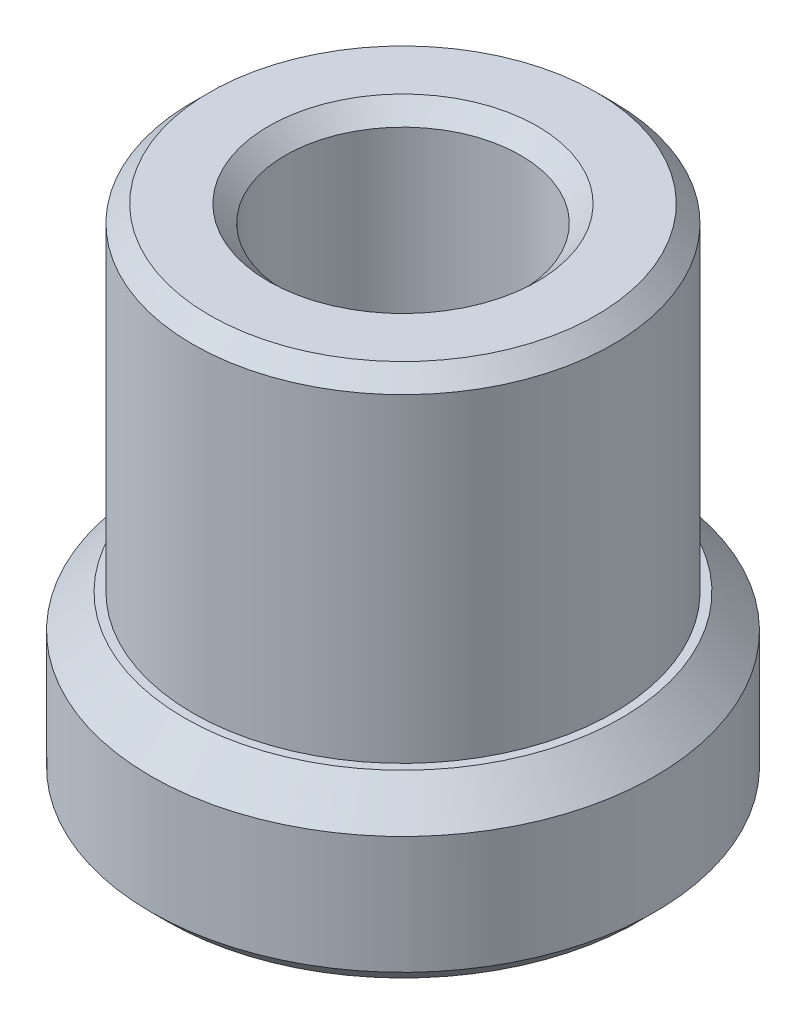
from build123d import *

# Parameters (mm, degrees)
CHAMFER_1_SIZE         = 1
CHAMFER_2_SIZE         = 2
HOLE_WIZARD_M161_D     = 14
HOLE_WIZARD_M161_DEPTH = 50
HOLE_WIZARD_M161_TIP   = 4.041451884
CHAMFER_3_SIZE         = 1


with BuildPart() as part:
    # Эскиз1 → Повернуть1 (revolve)
    with BuildSketch(Plane.XY):
        Polygon((0, 0), (-15, 0), (-15, 10), (-12.5, 10), (-12.5, 30), (0, 30), align=None)
    revolve(axis=Axis((0, 30, 0), (0, -1, 0)))

    # Фаска1
    chamfer_1_edges = [part.edges().sort_by_distance(p)[0] for p in [
        (12.5, 30, 0),
        (15, 0, 0),
    ]]
    chamfer(chamfer_1_edges, length=CHAMFER_1_SIZE)

    # Фаска2
    chamfer_2_edges = [part.edges().sort_by_distance(p)[0] for p in [
        (15, 10, 0),
    ]]
    chamfer(chamfer_2_edges, length=CHAMFER_2_SIZE)

    # Отверстие обработанное метчиком M161
    with Locations(Plane(origin=(0, 0, 0), x_dir=(-1, 0, 0), z_dir=(0, -1, 0))):
        with Locations((0, 0)):
            Hole(HOLE_WIZARD_M161_D / 2, depth=HOLE_WIZARD_M161_DEPTH)
            with Locations((0, 0, -(HOLE_WIZARD_M161_DEPTH + HOLE_WIZARD_M161_TIP / 2))):  # 120° drill point
                Cone(0, HOLE_WIZARD_M161_D / 2, HOLE_WIZARD_M161_TIP, mode=Mode.SUBTRACT)

    # Фаска3
    chamfer_3_edges = [part.edges().sort_by_distance(p)[0] for p in [
        (-7, 30, 0),
        (-7, 0, 0),
    ]]
    chamfer(chamfer_3_edges, length=CHAMFER_3_SIZE)


solid = part.part
